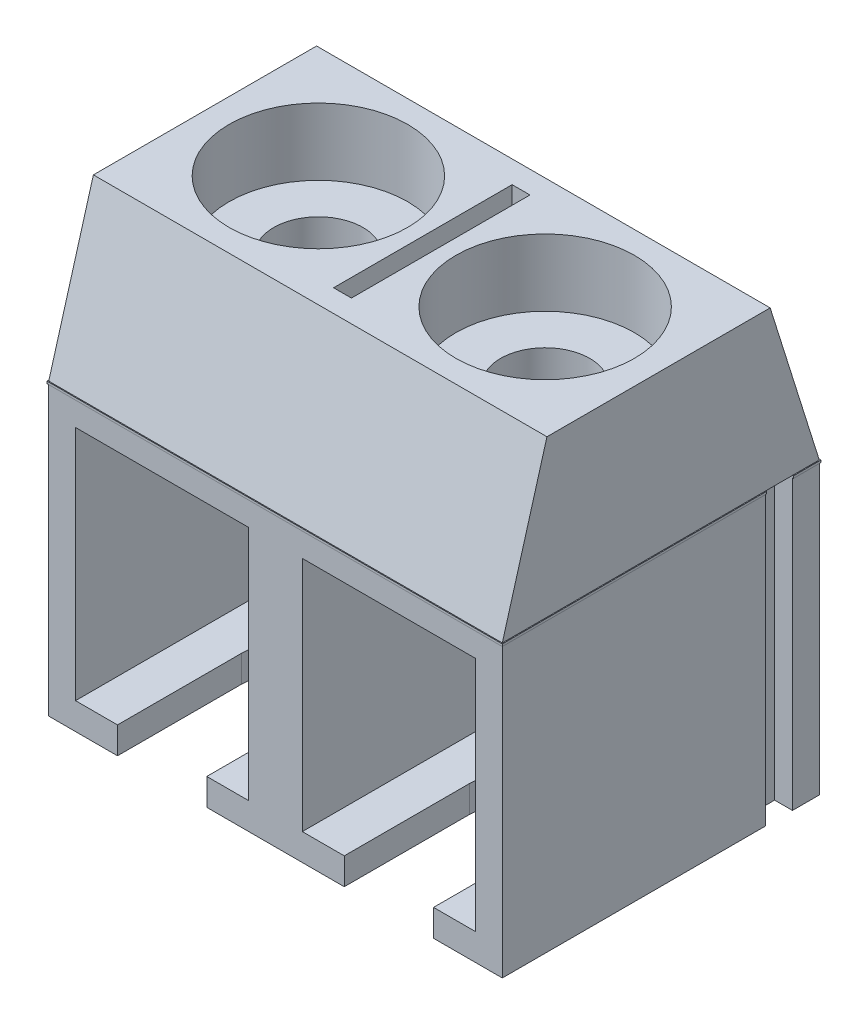
from build123d import *

# Parameters (mm, degrees)
SKETCH1_W            = 10.16
SKETCH1_H            = 7.1
BOSS_EXTRUDE1_DEPTH  = 6.5
SKETCH4_W            = 10.16
SKETCH4_H            = 5
SKETCH5_W            = 3.88
SKETCH5_H            = 5.3
CUT_EXTRUDE1_DEPTH   = 6.6
SKETCH6_R            = 2
SKETCH6_W            = 0.4
SKETCH6_H            = 4
CUT_EXTRUDE2_DEPTH   = 1.5
CUT_EXTRUDE3_REACH   = 10.5
SKETCH7_R            = 1
SKETCH8_W            = 0.6
SKETCH8_H            = 6.5
CUT_EXTRUDE4_DEPTH   = 0.4
SKETCH9_W            = 0.6
SKETCH9_H            = 6.5
BOSS_EXTRUDE2_DEPTH  = 0.4
SKETCH10_W           = 7.1
SKETCH10_H           = 0.05
BOSS_EXTRUDE3_DEPTH  = 0.02
SKETCH11_W           = 10.2
SKETCH11_H           = 0.05
BOSS_EXTRUDE4_DEPTH  = 0.02
SKETCH13_W           = 0.02
SKETCH13_H           = 0.05
BOSS_EXTRUDE8_DEPTH  = 5.9
SKETCH14_W           = 0.02
SKETCH14_H           = 0.05
BOSS_EXTRUDE9_DEPTH  = 0.02
SKETCH15_W           = 0.02
SKETCH15_H           = 0.05
BOSS_EXTRUDE10_DEPTH = 10.18
SKETCH16_W           = 0.02
SKETCH16_H           = 0.05
BOSS_EXTRUDE11_DEPTH = 0.6
CUT_EXTRUDE5_REACH   = 12


with BuildPart() as part:
    # Sketch1 → Boss-Extrude1 (new body)
    with BuildSketch(Plane(origin=(0, 0, 0), x_dir=(1, 0, 0), z_dir=(0, 1, 0))):
        with Locations((-5.08, -3.55)):
            Rectangle(SKETCH1_W, SKETCH1_H)
    extrude(amount=BOSS_EXTRUDE1_DEPTH)

    # Sketch4 → section 0 of loft1
    with BuildSketch(Plane(origin=(0, 10, 0), x_dir=(1, 0, 0), z_dir=(0, 1, 0)), mode=Mode.PRIVATE) as loft1_s0:
        with Locations((-5.08, -3.6)):
            Rectangle(SKETCH4_W, SKETCH4_H)
    # loft up to a face of the part (loft1)
    loft([loft1_s0.sketch, part.faces().sort_by_distance((-5.08, 6.5, 3.55))[0]])

    # Sketch5 → Cut-Extrude1 (cut)
    with BuildSketch(Plane.XY.offset(7.1)):
        with Locations((-7.62, 3.25)):
            Rectangle(SKETCH5_W, SKETCH5_H)
        with Locations((-2.54, 3.25)):
            Rectangle(SKETCH5_W, SKETCH5_H)
    extrude(amount=-CUT_EXTRUDE1_DEPTH, mode=Mode.SUBTRACT)

    # Sketch6 → Cut-Extrude2 (cut)
    with BuildSketch(Plane(origin=(0, 10, 0), x_dir=(1, 0, 0), z_dir=(0, 1, 0))):
        with Locations((-7.62, -3.6)):
            Circle(SKETCH6_R)
        with Locations((-2.54, -3.6)):
            Circle(SKETCH6_R)
        with Locations((-5.08, -3.6)):
            Rectangle(SKETCH6_W, SKETCH6_H)
    extrude(amount=-CUT_EXTRUDE2_DEPTH, mode=Mode.SUBTRACT)

    # Sketch7 → Cut-Extrude3 (cut, up to next)
    with BuildSketch(Plane(origin=(0, 8.5, 0), x_dir=(1, 0, 0), z_dir=(0, 1, 0)), mode=Mode.PRIVATE) as cut_extrude3_sk1:
        with Locations((-7.62, -3.6)):
            Circle(SKETCH7_R)
    cut_extrude3_tool1 = extrude(cut_extrude3_sk1.sketch, amount=-CUT_EXTRUDE3_REACH, mode=Mode.PRIVATE) & part.part
    add(cut_extrude3_tool1.solids().sort_by_distance((-7.62, 8.5, 3.6))[0], mode=Mode.SUBTRACT)
    # Sketch7 → Cut-Extrude3 (cut, up to next)
    with BuildSketch(Plane(origin=(0, 8.5, 0), x_dir=(1, 0, 0), z_dir=(0, 1, 0)), mode=Mode.PRIVATE) as cut_extrude3_sk2:
        with Locations((-2.54, -3.6)):
            Circle(SKETCH7_R)
    cut_extrude3_tool2 = extrude(cut_extrude3_sk2.sketch, amount=-CUT_EXTRUDE3_REACH, mode=Mode.PRIVATE) & part.part
    add(cut_extrude3_tool2.solids().sort_by_distance((-2.54, 8.5, 3.6))[0], mode=Mode.SUBTRACT)

    # Sketch8 → Cut-Extrude4 (cut)
    with BuildSketch(Plane(origin=(0, 0, 0), x_dir=(0, 0, -1), z_dir=(1, 0, 0))):
        with Locations((-0.9, 3.25)):
            Rectangle(SKETCH8_W, SKETCH8_H)
    extrude(amount=-CUT_EXTRUDE4_DEPTH, mode=Mode.SUBTRACT)

    # Sketch9 → Boss-Extrude2 (add)
    with BuildSketch(Plane.ZY.offset(10.16)):
        with Locations((0.9, 3.25)):
            Rectangle(SKETCH9_W, SKETCH9_H)
    extrude(amount=BOSS_EXTRUDE2_DEPTH)

    # Sketch10 → Boss-Extrude3 (add)
    with BuildSketch(Plane.ZY.offset(10.16)):
        with Locations((3.55, 6.475)):
            Rectangle(SKETCH10_W, SKETCH10_H)
    extrude(amount=BOSS_EXTRUDE3_DEPTH)

    # Sketch11 → Boss-Extrude4 (add)
    with BuildSketch(Plane.XY.offset(7.1)):
        with Locations((-5.08, 6.475)):
            Rectangle(SKETCH11_W, SKETCH11_H)
    extrude(amount=BOSS_EXTRUDE4_DEPTH)

    # Sketch13 → Boss-Extrude8 (add)
    with BuildSketch(Plane(origin=(0, 0, 7.1), x_dir=(-1, 0, 0), z_dir=(0, 0, -1))):
        with Locations((-0.01, 6.475)):
            Rectangle(SKETCH13_W, SKETCH13_H)
    extrude(amount=BOSS_EXTRUDE8_DEPTH)

    # Sketch14 → Boss-Extrude9 (add)
    with BuildSketch(Plane(origin=(0, 0, 0), x_dir=(-1, 0, 0), z_dir=(0, 0, -1))):
        with Locations((10.17, 6.475)):
            Rectangle(SKETCH14_W, SKETCH14_H)
    extrude(amount=BOSS_EXTRUDE9_DEPTH)

    # Sketch15 → Boss-Extrude10 (add)
    with BuildSketch(Plane(origin=(-10.16, 0, 0), x_dir=(0, 0, -1), z_dir=(1, 0, 0))):
        with Locations((0.01, 6.475)):
            Rectangle(SKETCH15_W, SKETCH15_H)
    extrude(amount=BOSS_EXTRUDE10_DEPTH)

    # Sketch16 → Boss-Extrude11 (add)
    with BuildSketch(Plane.XY):
        with Locations((0.01, 6.475)):
            Rectangle(SKETCH16_W, SKETCH16_H)
    extrude(amount=BOSS_EXTRUDE11_DEPTH)

    # Sketch18 → Cut-Extrude5 (cut, up to next)
    with BuildSketch(Plane.XZ, mode=Mode.PRIVATE) as cut_extrude5_sk1:
        with BuildLine():
            Line((-8.62, 4.32), (-8.62, 7.92))
            ThreePointArc((-8.62, 7.92), (-7.62, 8.92), (-6.62, 7.92))
            Line((-6.62, 7.92), (-6.62, 4.32))
            ThreePointArc((-6.62, 4.32), (-7.62, 3.32), (-8.62, 4.32))
        make_face()
    cut_extrude5_tool1 = extrude(cut_extrude5_sk1.sketch, amount=-CUT_EXTRUDE5_REACH, mode=Mode.PRIVATE) & part.part
    add(cut_extrude5_tool1.solids().sort_by_distance((-7.62, 0, 6.12))[0], mode=Mode.SUBTRACT)
    # Sketch18 → Cut-Extrude5 (cut, up to next)
    with BuildSketch(Plane.XZ, mode=Mode.PRIVATE) as cut_extrude5_sk2:
        with BuildLine():
            Line((-3.54, 4.3), (-3.54, 7.9))
            ThreePointArc((-3.54, 7.9), (-2.54, 8.9), (-1.54, 7.9))
            Line((-1.54, 7.9), (-1.54, 4.3))
            ThreePointArc((-1.54, 4.3), (-2.54, 3.3), (-3.54, 4.3))
        make_face()
    cut_extrude5_tool2 = extrude(cut_extrude5_sk2.sketch, amount=-CUT_EXTRUDE5_REACH, mode=Mode.PRIVATE) & part.part
    add(cut_extrude5_tool2.solids().sort_by_distance((-2.54, 0, 6.1))[0], mode=Mode.SUBTRACT)


solid = part.part
